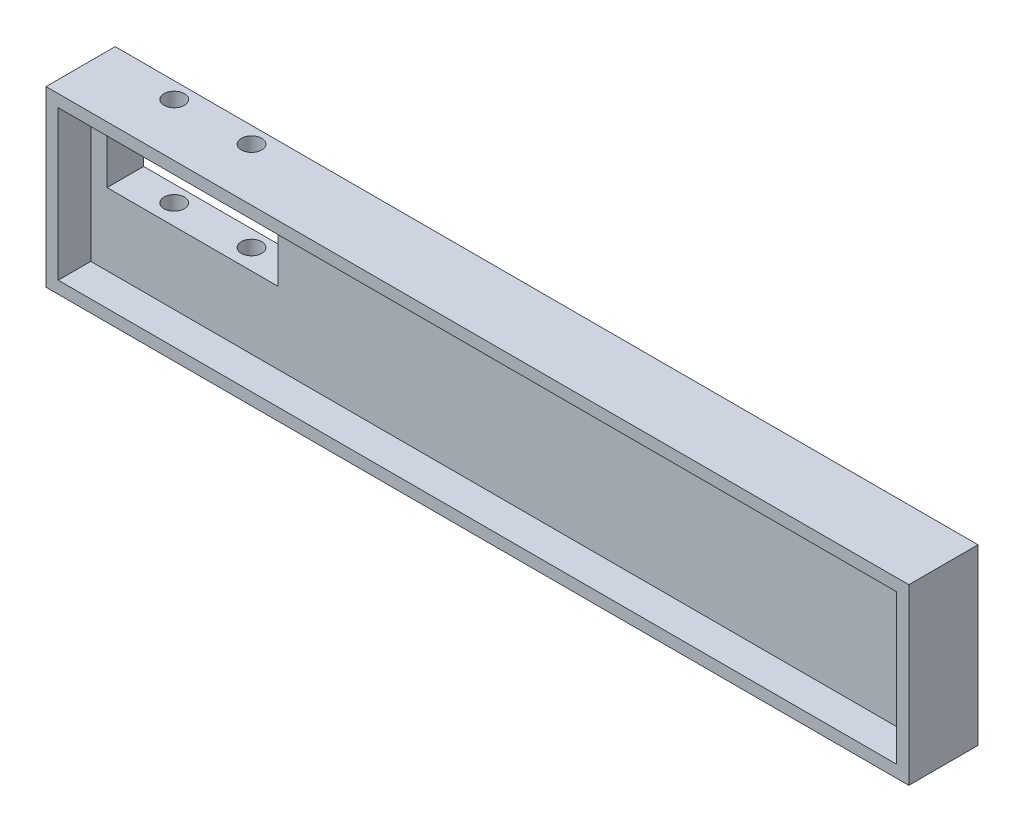
from build123d import *

# Parameters (mm, degrees)
RESSALTO_EXTRUS_O1_DEPTH = 5
ESBO_O1_4_W              = 106
ESBO_O1_4_H              = 21.35
ESBO_O1_4_W_2            = 21
ESBO_O1_4_H_2            = 7.5
RESSALTO_EXTRUS_O2_DEPTH = 3.5
CORTE_EXTRUS_O10_START   = -2.958856
ESBO_O3_R                = 1.25
CORTE_EXTRUS_O10_DEPTH   = 30
RESSALTO_EXTRUS_O4_DEPTH = 1


with BuildPart() as part:
    # Esboço1 → Ressalto-extrusão1 (new body)
    with BuildSketch(Plane.XY):
        Polygon((86, -2.958856089), (99, -2.958856089), (99, 18.391143911), (86, 18.391143911), (-7, 18.391143911), (-7, -2.958856089), align=None)
        Polygon((-5.5, 9.388435505), (-5.5, 16.891143911), (-3.5, 16.891143911), (17.5, 16.891143911), (87.5, 16.891143911), (97.5, 16.891143911), (97.5, -1.458856089), (87.5, -1.458856089), (-5.5, -1.458856089), align=None, mode=Mode.SUBTRACT)
    extrude(amount=RESSALTO_EXTRUS_O1_DEPTH)

    # Esboço1<4> → Ressalto-extrusão2 (add)
    with BuildSketch(Plane.XY):
        with Locations((46, 7.716143911)):
            Rectangle(ESBO_O1_4_W, ESBO_O1_4_H)
        with Locations((7, 11.141143911)):
            Rectangle(ESBO_O1_4_W_2, ESBO_O1_4_H_2, mode=Mode.SUBTRACT)
    extrude(amount=-RESSALTO_EXTRUS_O2_DEPTH)

    # Esboço3 → Corte-extrusão10 (cut)
    with BuildSketch(Plane(origin=(0, 0, 0), x_dir=(1, 0, 0), z_dir=(0, 1, 0)).offset(CORTE_EXTRUS_O10_START)):
        with Locations((2.25, 1.5)):
            Circle(ESBO_O3_R)
        with Locations((11.75, 1.5)):
            Circle(ESBO_O3_R)
    extrude(amount=CORTE_EXTRUS_O10_DEPTH, mode=Mode.SUBTRACT)

    # Esboço1<7> → Ressalto-extrusão4 (add)
    with BuildSketch(Plane.XY):
        Polygon((-3.5, 16.891143911), (-5.5, 16.891143911), (-5.5, 9.388435505), (-5.5, -1.458856089), (87.5, -1.458856089), (97.5, -1.458856089), (97.5, 16.891143911), (87.5, 16.891143911), (17.5, 16.891143911), align=None)
        Polygon((88, -0.958856089), (-5, -0.958856089), (-5, 16.391143911), (88, 16.391143911), (97, 16.391143911), (97, -0.958856089), align=None, mode=Mode.SUBTRACT)
        Polygon((97, -0.958856089), (88, -0.958856089), (-5, -0.958856089), (-5, 16.391143911), (88, 16.391143911), (97, 16.391143911), align=None)
        Polygon((17.5, 7.391143911), (17.5, 9.388435505), (17.5, 14.891143911), (-3.5, 14.891143911), (-3.5, 7.391143911), align=None, mode=Mode.SUBTRACT)
    extrude(amount=RESSALTO_EXTRUS_O4_DEPTH)


solid = part.part
